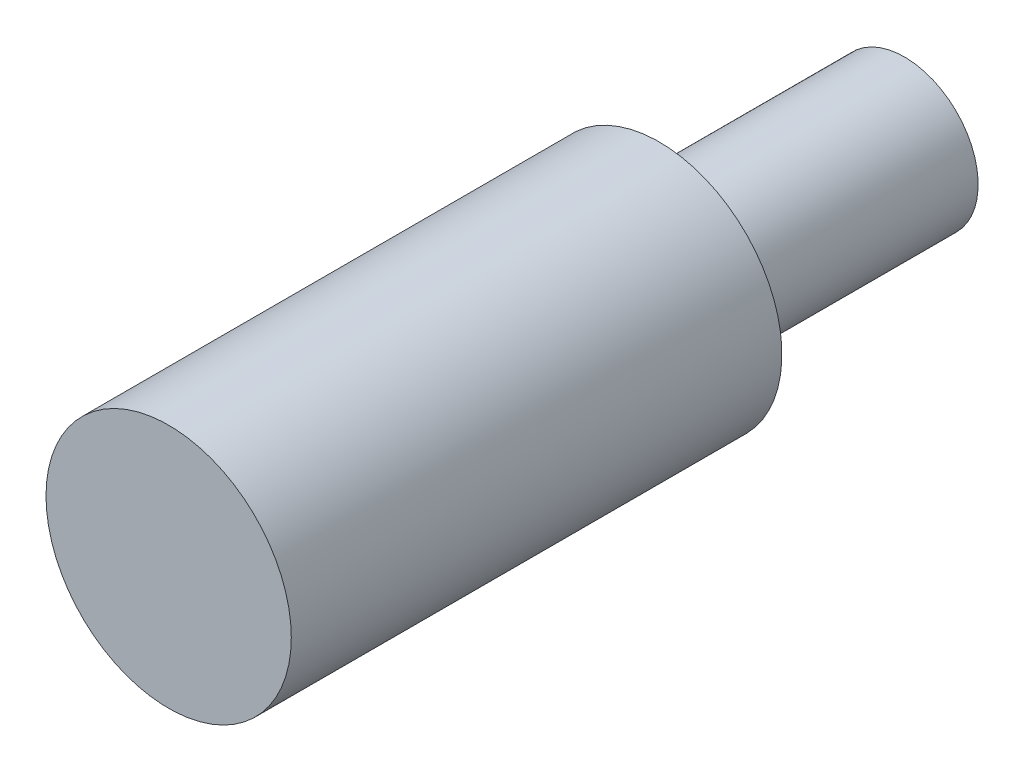
from build123d import *

# Parameters (mm, degrees)
SKETCH_1_R          = 25
EXTRUDE_1_DEPTH     = 150
SKETCH_2_R          = 25
SKETCH_2_R_2        = 15
CUT_EXTRUDE_1_DEPTH = 50


with BuildPart() as part:
    # ｽｹｯﾁ1 → ﾎﾞｽ - 押し出し1 (new body)
    with BuildSketch(Plane.XY):
        with Locations((0, 14.208011445)):
            Circle(SKETCH_1_R)
    extrude(amount=EXTRUDE_1_DEPTH)

    # ｽｹｯﾁ2 → ｶｯﾄ - 押し出し1 (cut)
    with BuildSketch(Plane(origin=(0, 0, 0), x_dir=(-1, 0, 0), z_dir=(0, 0, -1))):
        with Locations((0, 14.208011445)):
            Circle(SKETCH_2_R)
        with Locations((0, 14.208011445)):
            Circle(SKETCH_2_R_2, mode=Mode.SUBTRACT)
    extrude(amount=-CUT_EXTRUDE_1_DEPTH, mode=Mode.SUBTRACT)


solid = part.part
